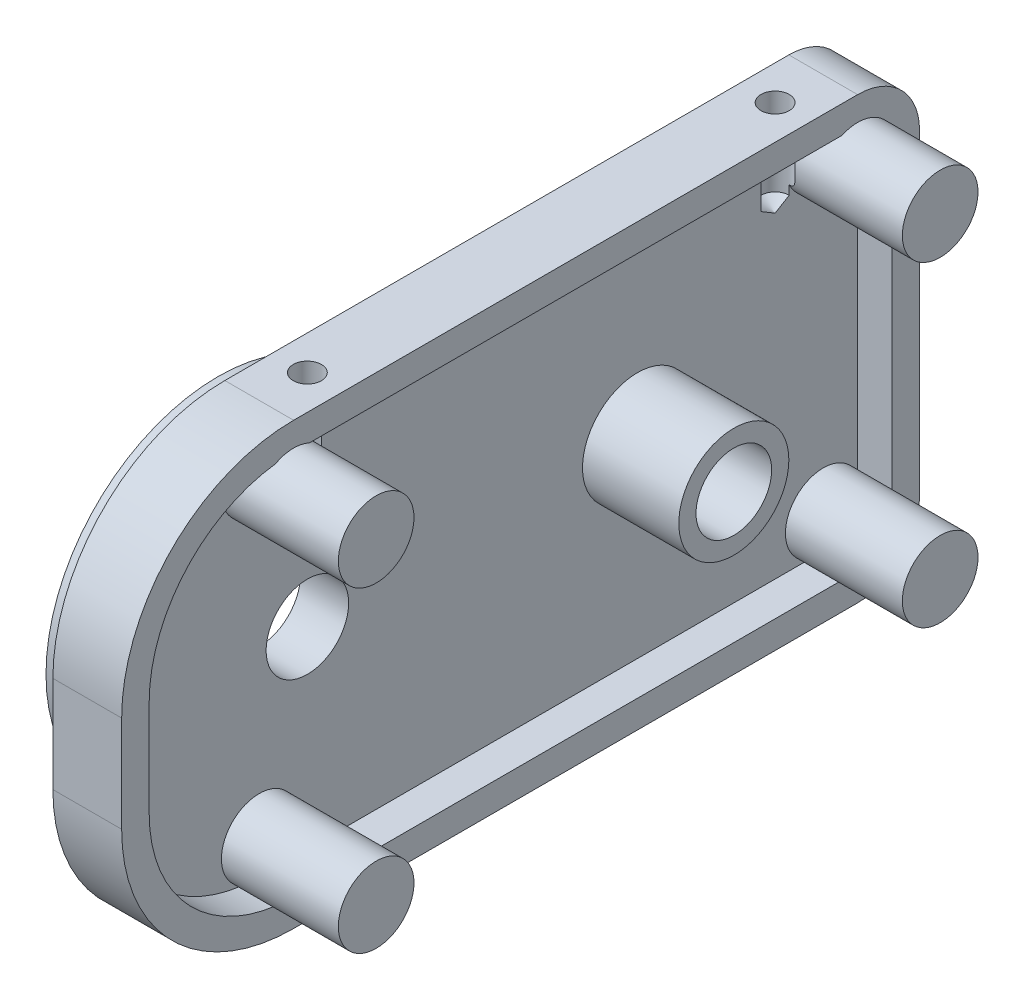
from build123d import *

# Parameters (mm, degrees)
SKETCH1_W                    = 58
SKETCH1_H                    = 32
SKETCH1_R                    = 2.75
BOSS_EXTRUDE1_DEPTH          = 5
SKETCH2_R                    = 4
SKETCH2_R_2                  = 2.75
BOSS_EXTRUDE2_DEPTH          = 4.5
FILLET1_R                    = 4.5
FILLET2_R                    = 12.5
SKETCH4_R                    = 2.75
BOSS_EXTRUDE3_DEPTH          = 6
SKETCH8_R                    = 12.5
BOSS_EXTRUDE4_DEPTH          = 4
SKETCH9_R                    = 10
CUT_EXTRUDE2_DEPTH           = 3
SKETCH10_R                   = 3
CUT_EXTRUDE3_DEPTH           = 13
SKETCH3_R                    = 4
CUT_EXTRUDE1_DEPTH           = 2.5
M2_5X0_45_TAPPED_HOLE1_D     = 2.05
M2_5X0_45_TAPPED_HOLE1_DEPTH = 6.35
M2_5X0_45_TAPPED_HOLE1_TIP   = 0.615882135


with BuildPart() as part:
    # Sketch1 → Boss-Extrude1 (new body)
    with BuildSketch(Plane(origin=(0, 0, 0), x_dir=(0, 0, -1), z_dir=(1, 0, 0))):
        Rectangle(SKETCH1_W, SKETCH1_H)
        with Locations((11, 0)):
            Circle(SKETCH1_R, mode=Mode.SUBTRACT)
    extrude(amount=BOSS_EXTRUDE1_DEPTH)

    # Sketch2 → Boss-Extrude2 (add)
    with BuildSketch(Plane(origin=(5, 0, 0), x_dir=(0, 0, -1), z_dir=(1, 0, 0))):
        with Locations((11, 0)):
            Circle(SKETCH2_R)
        with Locations((11, 0)):
            Circle(SKETCH2_R_2, mode=Mode.SUBTRACT)
    extrude(amount=BOSS_EXTRUDE2_DEPTH)

    # Fillet1
    fillet1_edges = [part.edges().sort_by_distance(p)[0] for p in [
        (2.5, 16, -29),
        (2.5, -16, -29),
    ]]
    fillet(fillet1_edges, radius=FILLET1_R)

    # Fillet2
    fillet2_edges = [part.edges().sort_by_distance(p)[0] for p in [
        (2.5, -16, 29),
        (2.5, 16, 29),
    ]]
    fillet(fillet2_edges, radius=FILLET2_R)

    # Sketch4 → Boss-Extrude3 (add)
    with BuildSketch(Plane(origin=(5, 0, 0), x_dir=(0, 0, -1), z_dir=(1, 0, 0))):
        with Locations((24.5, 11.5)):
            Circle(SKETCH4_R)
        with Locations((24.5, -11.5)):
            Circle(SKETCH4_R)
        with Locations((-16.5, 11.5)):
            Circle(SKETCH4_R)
        with Locations((-16.5, -11.5)):
            Circle(SKETCH4_R)
    extrude(amount=BOSS_EXTRUDE3_DEPTH)

    # Sketch8 → Boss-Extrude4 (add)
    with BuildSketch(Plane.ZY):
        with Locations((13, 0)):
            Circle(SKETCH8_R)
    extrude(amount=BOSS_EXTRUDE4_DEPTH)

    # Sketch9 → Cut-Extrude2 (cut)
    with BuildSketch(Plane.ZY.offset(4)):
        with Locations((13, 0)):
            Circle(SKETCH9_R)
    extrude(amount=-CUT_EXTRUDE2_DEPTH, mode=Mode.SUBTRACT)

    # Sketch10 → Cut-Extrude3 (cut, through all)
    with BuildSketch(Plane.ZY.offset(1)):
        with Locations((13, 0)):
            Circle(SKETCH10_R)
    extrude(amount=-CUT_EXTRUDE3_DEPTH, mode=Mode.SUBTRACT)

    # Sketch3 → Cut-Extrude1 (cut)
    with BuildSketch(Plane(origin=(5, 0, 0), x_dir=(0, 0, -1), z_dir=(1, 0, 0))):
        with BuildLine():
            ThreePointArc((-17.809934015, 13.91796875), (-24.374144625, 10.446066975), (-27, 3.5))
            Line((-27, 3.5), (-27, -3.5))
            ThreePointArc((-27, -3.5), (-24.374144625, -10.446066975), (-17.809934015, -13.91796875))
            ThreePointArc((-17.809934015, -13.91796875), (-17.907156967, -9.13728773), (-13.75, -11.5))
            ThreePointArc((-13.75, -11.5), (-14.185586382, -12.98525742), (-15.354356076, -14))
            Line((-15.354356076, -14), (23.354356076, -14))
            ThreePointArc((23.354356076, -14), (22.555456352, -9.555456352), (27, -10.354356076))
            Line((27, -10.354356076), (27, 10.354356076))
            ThreePointArc((27, 10.354356076), (22.555456352, 9.555456352), (23.354356076, 14))
            Line((23.354356076, 14), (-15.354356076, 14))
            ThreePointArc((-15.354356076, 14), (-14.185586382, 12.98525742), (-13.75, 11.5))
            ThreePointArc((-13.75, 11.5), (-17.907156967, 9.13728773), (-17.809934015, 13.91796875))
        make_face()
        with Locations((11, 0)):
            Circle(SKETCH3_R, mode=Mode.SUBTRACT)
    extrude(amount=-CUT_EXTRUDE1_DEPTH, mode=Mode.SUBTRACT)

    # M2.5x0.45 Tapped Hole1
    with Locations(Plane(origin=(0, 16, 0), x_dir=(1, 0, 0), z_dir=(0, 1, 0))):
        with Locations((2.5, 21), (2.5, -13)):
            Hole(M2_5X0_45_TAPPED_HOLE1_D / 2, depth=M2_5X0_45_TAPPED_HOLE1_DEPTH)
            with Locations((0, 0, -(M2_5X0_45_TAPPED_HOLE1_DEPTH + M2_5X0_45_TAPPED_HOLE1_TIP / 2))):  # 118° drill point
                Cone(0, M2_5X0_45_TAPPED_HOLE1_D / 2, M2_5X0_45_TAPPED_HOLE1_TIP, mode=Mode.SUBTRACT)


solid = part.part
